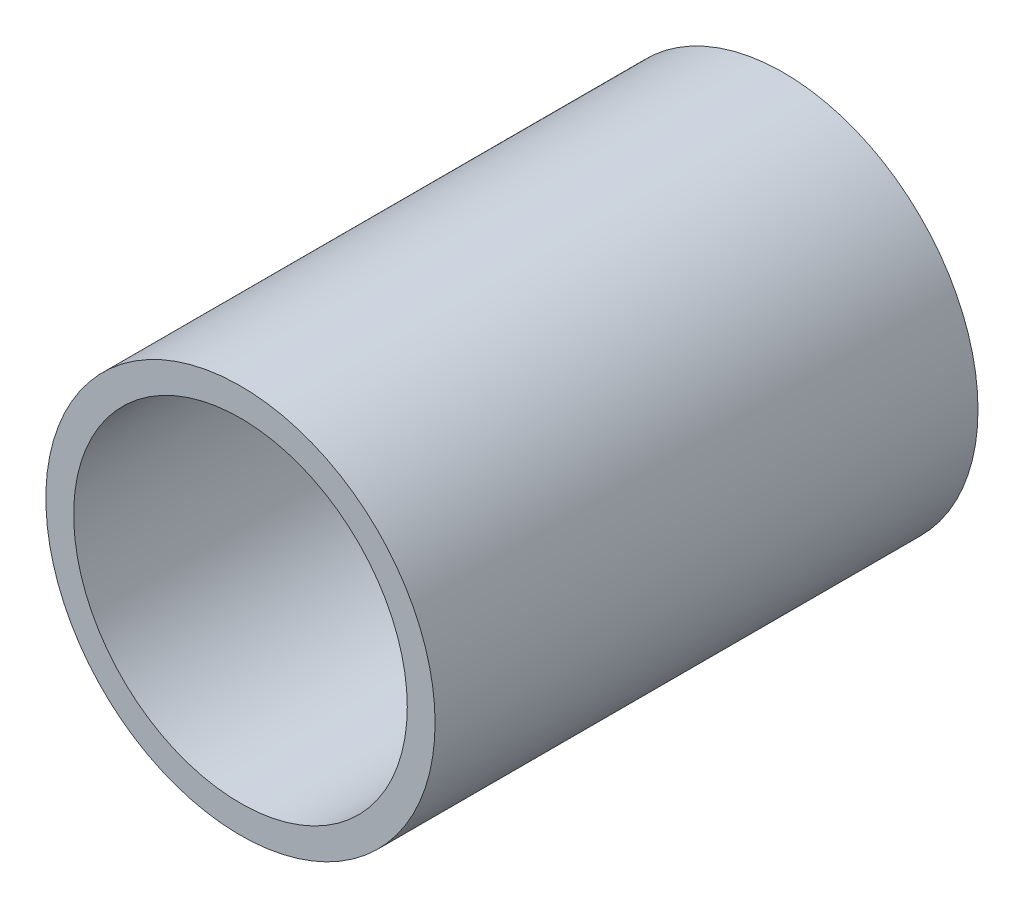
from build123d import *

# Parameters (mm, degrees)
SKETCH1_R           = 44.45
SKETCH1_R_2         = 38.1
BOSS_EXTRUDE1_DEPTH = 62


with BuildPart() as part:
    # Sketch1 → Boss-Extrude1 (new body, symmetric)
    with BuildSketch(Plane.XY):
        Circle(SKETCH1_R)
        Circle(SKETCH1_R_2, mode=Mode.SUBTRACT)
    extrude(amount=BOSS_EXTRUDE1_DEPTH, both=True)


solid = part.part
